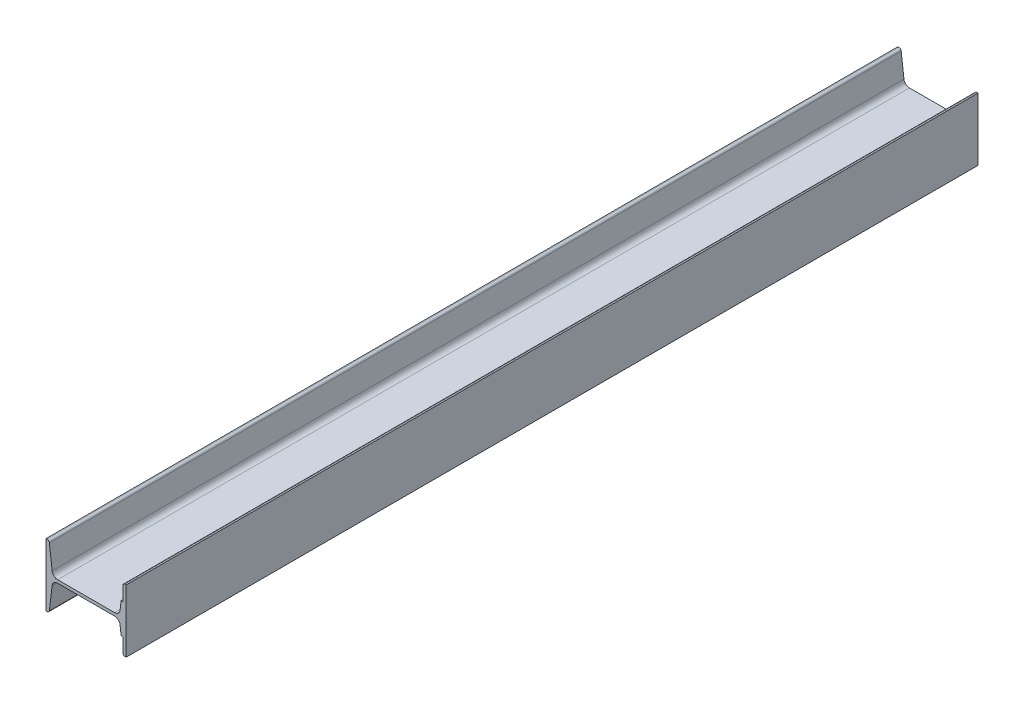
from build123d import *

# Parameters (mm, degrees)
BOSS_EXTRUDE1_DEPTH = 1700
SCALE1_SCALE        = 0.75


with BuildPart() as part:
    # Sketch1 → Boss-Extrude1 (new body)
    with BuildSketch(Plane.XY.offset(1800)):
        with BuildLine():
            Line((129, 60.46884946), (129, 30))
            Line((129, 30), (124.919748757, 30))
            Line((124.919748757, 30), (122.792728308, 12.689402566))
            ThreePointArc((122.792728308, 12.689402566), (119.171200489, 5.771495525), (111.871083085, 3))
            Line((111.871083085, 3), (-1.871083085, 3))
            ThreePointArc((-1.871083085, 3), (-9.171200492, 5.771495528), (-12.792728309, 12.689402573))
            Line((-12.792728309, 12.689402573), (-18.294338419, 58.536153493))
            ThreePointArc((-18.294338419, 58.536153493), (-19.775872526, 61.366206375), (-22.762284192, 62.5))
            Line((-22.762284192, 62.5), (-25, 62.5))
            Line((-25, 62.5), (-25, -62.5))
            Line((-25, -62.5), (-22.762284192, -62.5))
            ThreePointArc((-22.762284192, -62.5), (-19.775872526, -61.366206375), (-18.294338419, -58.536153493))
            Line((-18.294338419, -58.536153493), (-12.792728309, -12.689402573))
            ThreePointArc((-12.792728309, -12.689402573), (-9.171200492, -5.771495528), (-1.871083085, -3))
            Line((-1.871083085, -3), (111.871083085, -3))
            ThreePointArc((111.871083085, -3), (119.171200492, -5.771495528), (122.792728309, -12.689402573))
            Line((122.792728309, -12.689402573), (124.87, -30))
            Line((124.87, -30), (129, -30))
            Line((129, -30), (129, -60.46884946))
            ThreePointArc((129, -60.46884946), (130.62450761, -61.959786773), (132.762284192, -62.5))
            Line((132.762284192, -62.5), (135, -62.5))
            Line((135, -62.5), (135, 62.5))
            Line((135, 62.5), (132.762284192, 62.5))
            ThreePointArc((132.762284192, 62.5), (130.62450761, 61.959786773), (129, 60.46884946))
        make_face()
    extrude(amount=-BOSS_EXTRUDE1_DEPTH)


with BuildPart() as part_1:
    # Scale1: scaled about (51.838667986, -0.00324275, 950)
    add(part.part.scale(SCALE1_SCALE).moved(Location((12.959666996, -0.000810687, 237.5))))


solid = part_1.part
